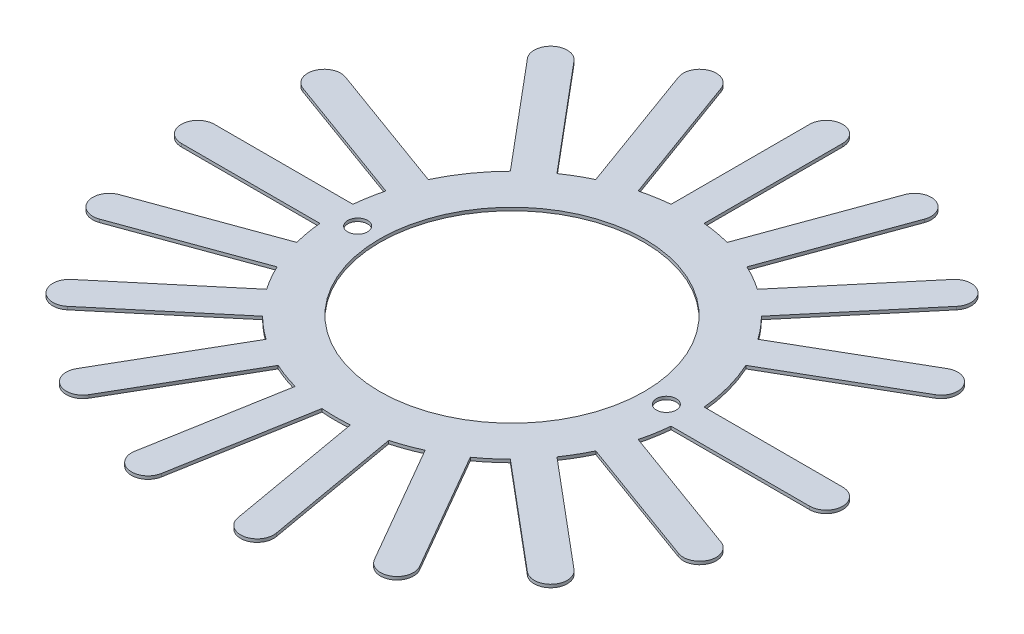
from build123d import *

# Parameters (mm, degrees)
SKETCH1_R                      = 8
BOSS_EXTRUDE2_DEPTH            = 0.14
BOSS_EXTRUDE3_DEPTH            = 0.14
CIRPATTERN3_COUNT              = 11
CIRPATTERN3_ANGLE              = 200
BOSS_EXTRUDE4_DEPTH            = 0.14
CIRPATTERN4_COUNT              = 6
CIRPATTERN4_ANGLE              = 100
CUT_EXTRUDE3_REACH             = 2.14
SKETCH2_R                      = 6
F_0_9_0_9_DIAMETER_HOLE1_D     = 0.9
F_0_9_0_9_DIAMETER_HOLE1_DEPTH = 0.14


with BuildPart() as part:
    # Sketch1 → Boss-Extrude2 (new body)
    with BuildSketch(Plane(origin=(0, 0, 0), x_dir=(1, 0, 0), z_dir=(0, 1, 0))):
        Circle(SKETCH1_R)
    extrude(amount=BOSS_EXTRUDE2_DEPTH)

    # Sketch3 → Boss-Extrude3 (add)
    with BuildSketch(Plane(origin=(0, 0.14, 0), x_dir=(1, 0, 0), z_dir=(0, 1, 0))):
        with BuildLine():
            Line((7.964766161, -0.75), (14.25, -0.75))
            ThreePointArc((14.25, -0.75), (15, 0), (14.25, 0.75))
            Line((14.25, 0.75), (7.964766161, 0.75))
            ThreePointArc((7.964766161, 0.75), (8, 0), (7.964766161, -0.75))
        make_face()
    boss_extrude3 = extrude(amount=-BOSS_EXTRUDE3_DEPTH)

    # CirPattern3: Boss-Extrude3 ×11 about axis
    cirpattern3_axis = Axis((0, 0, 0), (0, -1, 0))
    for i in range(1, CIRPATTERN3_COUNT):
        add(boss_extrude3.rotate(cirpattern3_axis, i * CIRPATTERN3_ANGLE / (CIRPATTERN3_COUNT - 1)))

    # Sketch5 → Boss-Extrude4 (add)
    with BuildSketch(Plane(origin=(0, 0.14, 0), x_dir=(1, 0, 0), z_dir=(0, 1, 0))):
        with BuildLine():
            Line((7.272689831, 3.332864028), (12.715862004, 6.475480947))
            ThreePointArc((12.715862004, 6.475480947), (12.990381057, 7.5), (11.965862004, 7.774519053))
            Line((11.965862004, 7.774519053), (6.522689831, 4.631902133))
            ThreePointArc((6.522689831, 4.631902133), (6.92820323, 4), (7.272689831, 3.332864028))
        make_face()
    boss_extrude4 = extrude(amount=-BOSS_EXTRUDE4_DEPTH)

    # CirPattern4: Boss-Extrude4 ×6 about axis
    cirpattern4_axis = Axis((0, 0, 0), (0, 1, 0))
    for i in range(1, CIRPATTERN4_COUNT):
        add(boss_extrude4.rotate(cirpattern4_axis, i * CIRPATTERN4_ANGLE / (CIRPATTERN4_COUNT - 1)))

    # Sketch2 → Cut-Extrude3 (cut, up to next)
    with BuildSketch(Plane(origin=(0, 0.14, 0), x_dir=(1, 0, 0), z_dir=(0, 1, 0)), mode=Mode.PRIVATE) as cut_extrude3_sk1:
        Circle(SKETCH2_R)
    cut_extrude3_tool1 = extrude(cut_extrude3_sk1.sketch, amount=-CUT_EXTRUDE3_REACH, mode=Mode.PRIVATE) & part.part
    add(cut_extrude3_tool1.solids().sort_by_distance((0, 0.14, 0))[0], mode=Mode.SUBTRACT)

    # Ø0.9 (0.9) Diameter Hole1
    with Locations(Plane(origin=(0, 0.14, 0), x_dir=(1, 0, 0), z_dir=(0, 1, 0))):
        with Locations((-7, 0), (7, 0)):
            Hole(F_0_9_0_9_DIAMETER_HOLE1_D / 2, depth=F_0_9_0_9_DIAMETER_HOLE1_DEPTH)


solid = part.part
